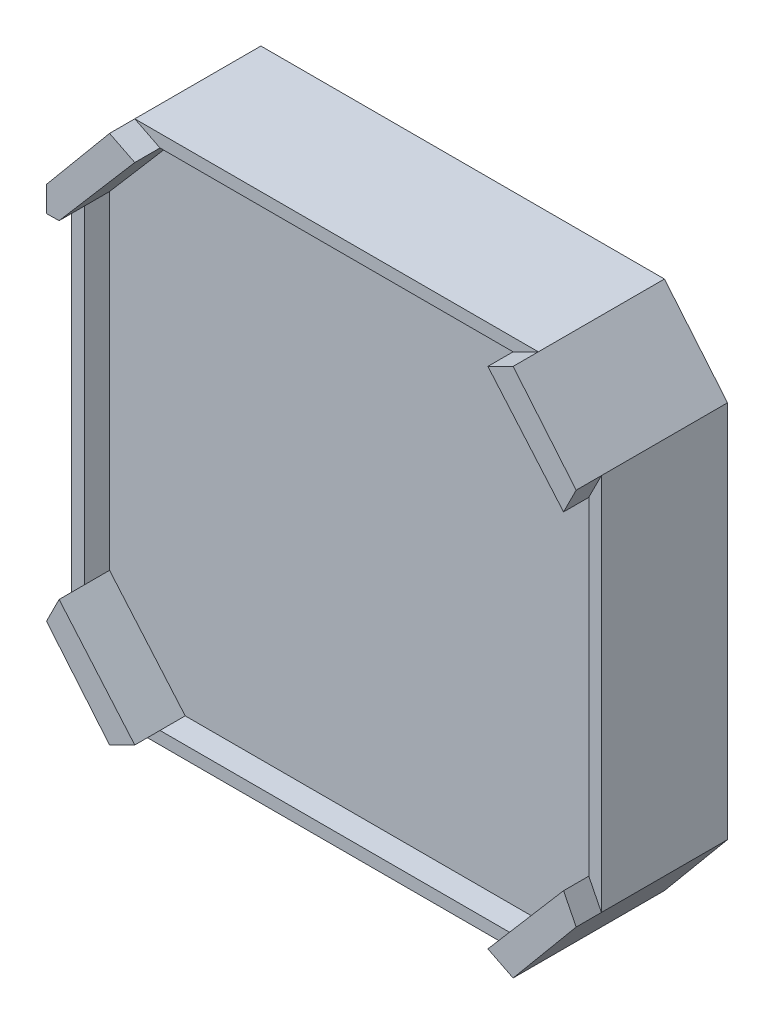
from build123d import *

# Parameters (mm, degrees)
SALIENTE_EXTRUIR1_DEPTH = 10
CORTAR_EXTRUIR1_DEPTH   = 2
SALIENTE_EXTRUIR2_DEPTH = 2
CROQUIS5_W              = 4
CROQUIS5_H              = 3
CORTAR_EXTRUIR2_DEPTH   = 3
CROQUIS6_R              = 1.4
CORTAR_EXTRUIR3_DEPTH   = 5


with BuildPart() as part:
    # Croquis2 → Saliente-Extruir1 (new body)
    with BuildSketch(Plane.XY):
        Polygon((-16, 21), (16, 21), (21, 15), (21, -15), (16, -21), (-16, -21), (-21, -15), (-21, 15), align=None)
    extrude(amount=SALIENTE_EXTRUIR1_DEPTH)

    # Croquis3 → Cortar-Extruir1 (cut)
    with BuildSketch(Plane.XY.offset(10)):
        Polygon((-14, 20), (14, 20), (20, 13.004934109), (20, -13.004934109), (14, -20), (-14, -20), (-20, -13.004934109), (-20, 13.004934109), align=None)
    extrude(amount=-CORTAR_EXTRUIR1_DEPTH, mode=Mode.SUBTRACT)

    # Croquis4 → Saliente-Extruir2 (add)
    with BuildSketch(Plane.XY.offset(10)):
        Polygon((-16, -21), (-14, -20), (-20, -13.004934109), (-21, -15), align=None)
        Polygon((-20, 13.004934109), (-14, 20), (-16, 21), (-21, 15), (-21, 12.992008233), align=None)
        Polygon((16, 21), (21, 15), (20, 13.004934109), (14, 20), align=None)
        Polygon((16, -21), (21, -15), (20, -13.004934109), (14, -20), align=None)
    extrude(amount=SALIENTE_EXTRUIR2_DEPTH)

    # Croquis5 → Cortar-Extruir2 (cut)
    with BuildSketch(Plane.XZ.offset(21)):
        with Locations((0, 5)):
            Rectangle(CROQUIS5_W, CROQUIS5_H)
    extrude(amount=-CORTAR_EXTRUIR2_DEPTH, mode=Mode.SUBTRACT)

    # Croquis6 → Cortar-Extruir3 (cut)
    with BuildSketch(Plane(origin=(0, 0, 0), x_dir=(-1, 0, 0), z_dir=(0, 0, -1))):
        with Locations((15.5, 15.5)):
            Circle(CROQUIS6_R)
        with Locations((-15.5, 15.5)):
            Circle(CROQUIS6_R)
        with Locations((15.5, -15.5)):
            Circle(CROQUIS6_R)
        with Locations((-15.5, -15.5)):
            Circle(CROQUIS6_R)
    extrude(amount=-CORTAR_EXTRUIR3_DEPTH, mode=Mode.SUBTRACT)


solid = part.part
